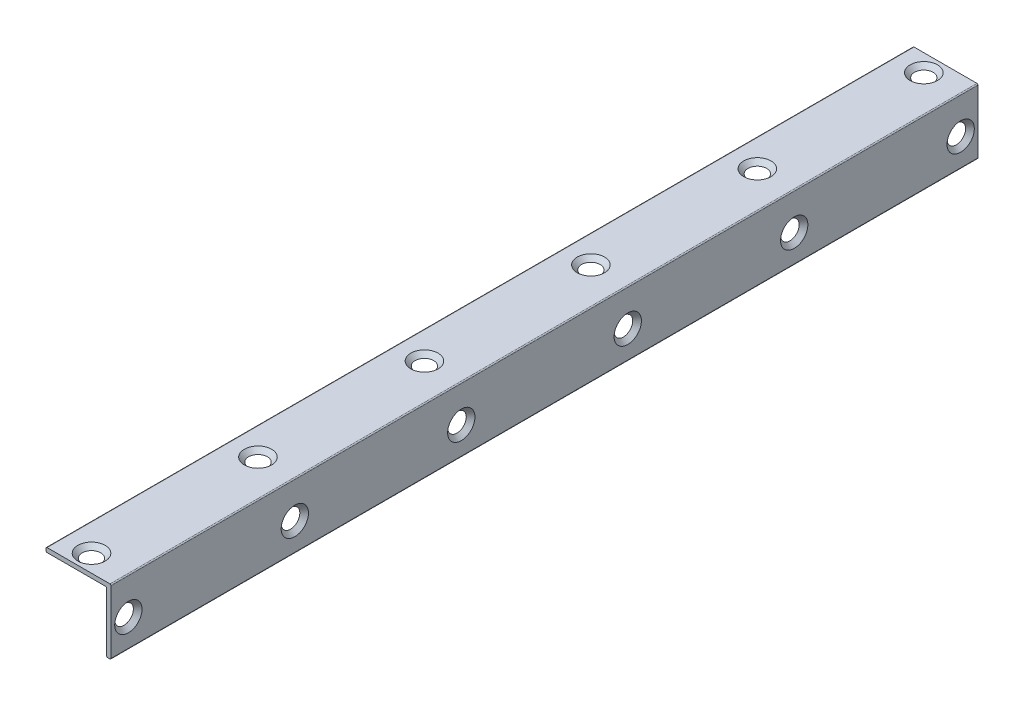
from build123d import *

# Parameters (mm, degrees)
EXTRUDE1_DEPTH  = 200
FILLET1_R       = 0.25
LPATTERN1_COUNT = 6
LPATTERN1_PITCH = 38.4
LPATTERN2_COUNT = 6
LPATTERN2_PITCH = 38.4


with BuildPart() as part:
    # Sketch1 → Extrude1 (new body)
    with BuildSketch(Plane.XY):
        Polygon((0, 0), (0, 15), (-15, 15), (-15, 14), (-1, 14), (-1, 0), align=None)
    extrude(amount=EXTRUDE1_DEPTH)

    # Fillet1
    fillet1_edges = [part.edges().sort_by_distance(p)[0] for p in [
        (-15, 14, 100),
        (-15, 15, 100),
        (0, 15, 100),
        (0, 0, 100),
        (-1, 0, 100),
    ]]
    fillet(fillet1_edges, radius=FILLET1_R)

    # Sketch3 → CSK for M3 Countersunk Flat Head Screw1 (revolve, cut)
    with BuildSketch(Plane(origin=(0, 6.5, 4), x_dir=(0, 0, -1), z_dir=(0, 1, 0))):
        Polygon((0, 0), (0, 1.001), (1.7, 1.001), (1.7, 1.45), (3.15, 0), align=None)
    csk_for_m3_countersunk_flat_head_screw1 = revolve(axis=Axis((6.35, 6.5, 4), (-1, 0, 0)), mode=Mode.SUBTRACT)

    # LPattern1: CSK for M3 Countersunk Flat Head Screw1 ×6
    with Locations(*[(0, 0, i * LPATTERN1_PITCH) for i in range(1, LPATTERN1_COUNT)]):
        add(csk_for_m3_countersunk_flat_head_screw1, mode=Mode.SUBTRACT)

    # Sketch5 → CSK for M3 Countersunk Flat Head Screw2 (revolve, cut)
    with BuildSketch(Plane(origin=(-8.5, 15, 4), x_dir=(0, 0, 1), z_dir=(1, 0, 0))):
        Polygon((0, 0), (0, 1.001), (1.7, 1.001), (1.7, 1.45), (3.15, 0), align=None)
    csk_for_m3_countersunk_flat_head_screw2 = revolve(axis=Axis((-8.5, 21.35, 4), (0, -1, 0)), mode=Mode.SUBTRACT)

    # LPattern2: CSK for M3 Countersunk Flat Head Screw2 ×6
    with Locations(*[(0, 0, i * LPATTERN2_PITCH) for i in range(1, LPATTERN2_COUNT)]):
        add(csk_for_m3_countersunk_flat_head_screw2, mode=Mode.SUBTRACT)


solid = part.part
